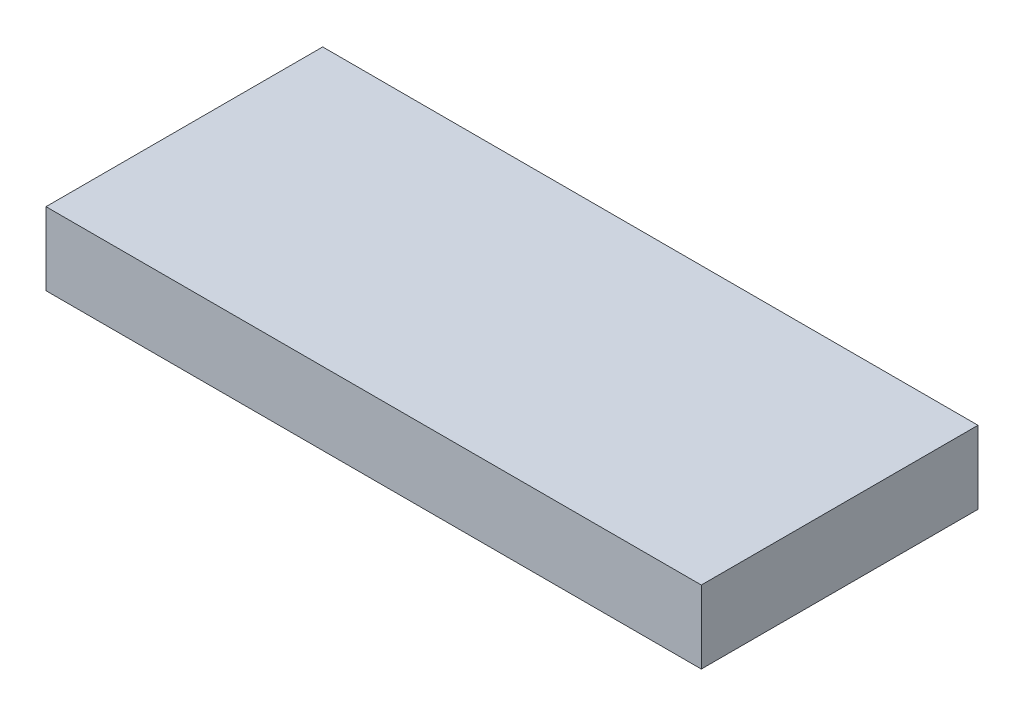
from build123d import *

# Parameters (mm, degrees)
SKETCH1_W           = 57.15
SKETCH1_H           = 24.13
BOSS_EXTRUDE1_DEPTH = 6.35


with BuildPart() as part:
    # Sketch1 → Boss-Extrude1 (new body)
    with BuildSketch(Plane(origin=(0, 0, 0), x_dir=(1, 0, 0), z_dir=(0, 1, 0))):
        with Locations((28.575, -12.065)):
            Rectangle(SKETCH1_W, SKETCH1_H)
    extrude(amount=BOSS_EXTRUDE1_DEPTH)


solid = part.part
